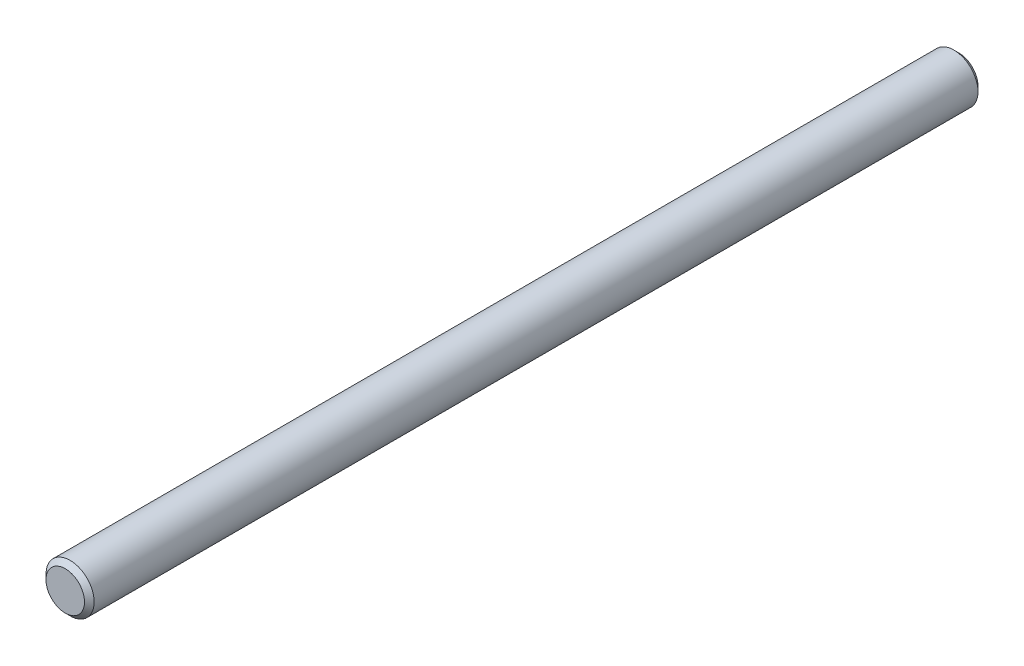
from build123d import *

# Parameters (mm, degrees)
SKETCH1_R      = 15.875
EXTRUDE1_DEPTH = 294.64
CHAMFER1_SIZE  = 3.175


with BuildPart() as part:
    # Sketch1 → Extrude1 (new body, symmetric)
    with BuildSketch(Plane.XY):
        Circle(SKETCH1_R)
    extrude(amount=EXTRUDE1_DEPTH, both=True)

    # Chamfer1
    chamfer1_edges = [part.edges().sort_by_distance(p)[0] for p in [
        (-15.875, 0, -294.64),
        (-15.875, 0, 294.64),
    ]]
    chamfer(chamfer1_edges, length=CHAMFER1_SIZE)


solid = part.part
